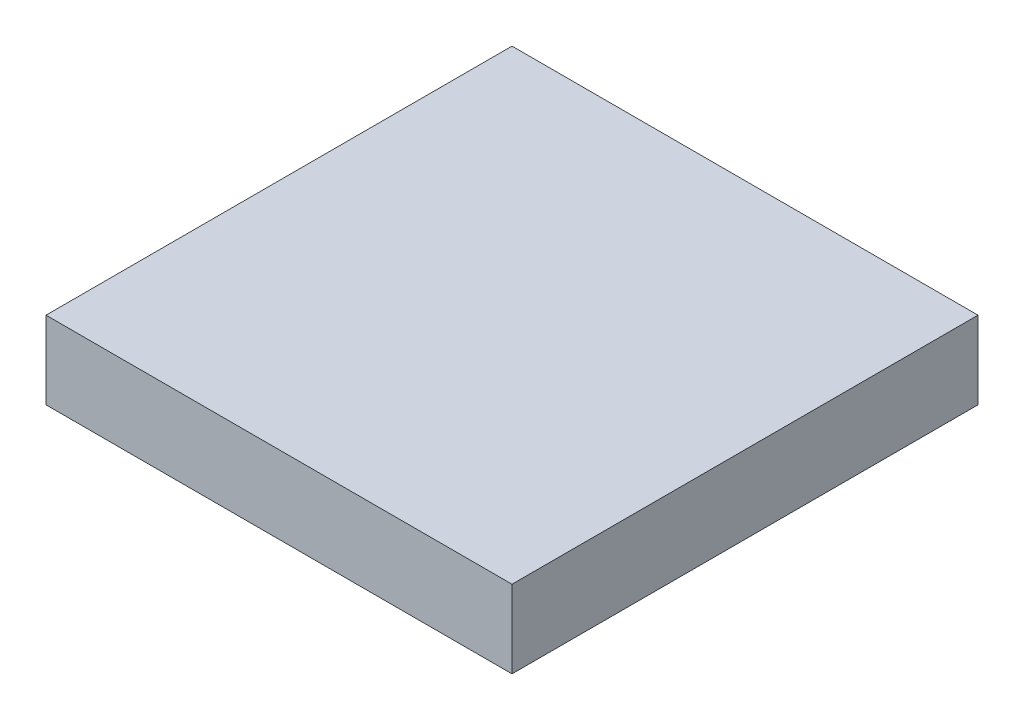
from build123d import *

# Parameters (mm, degrees)
SKETCH5_W           = 60
SKETCH5_H           = 60
BOSS_EXTRUDE2_DEPTH = 10


with BuildPart() as part:
    # Sketch5 → Boss-Extrude2 (new body)
    with BuildSketch(Plane(origin=(0, 0, 0), x_dir=(1, 0, 0), z_dir=(0, 1, 0))):
        Rectangle(SKETCH5_W, SKETCH5_H)
    extrude(amount=BOSS_EXTRUDE2_DEPTH)


solid = part.part
